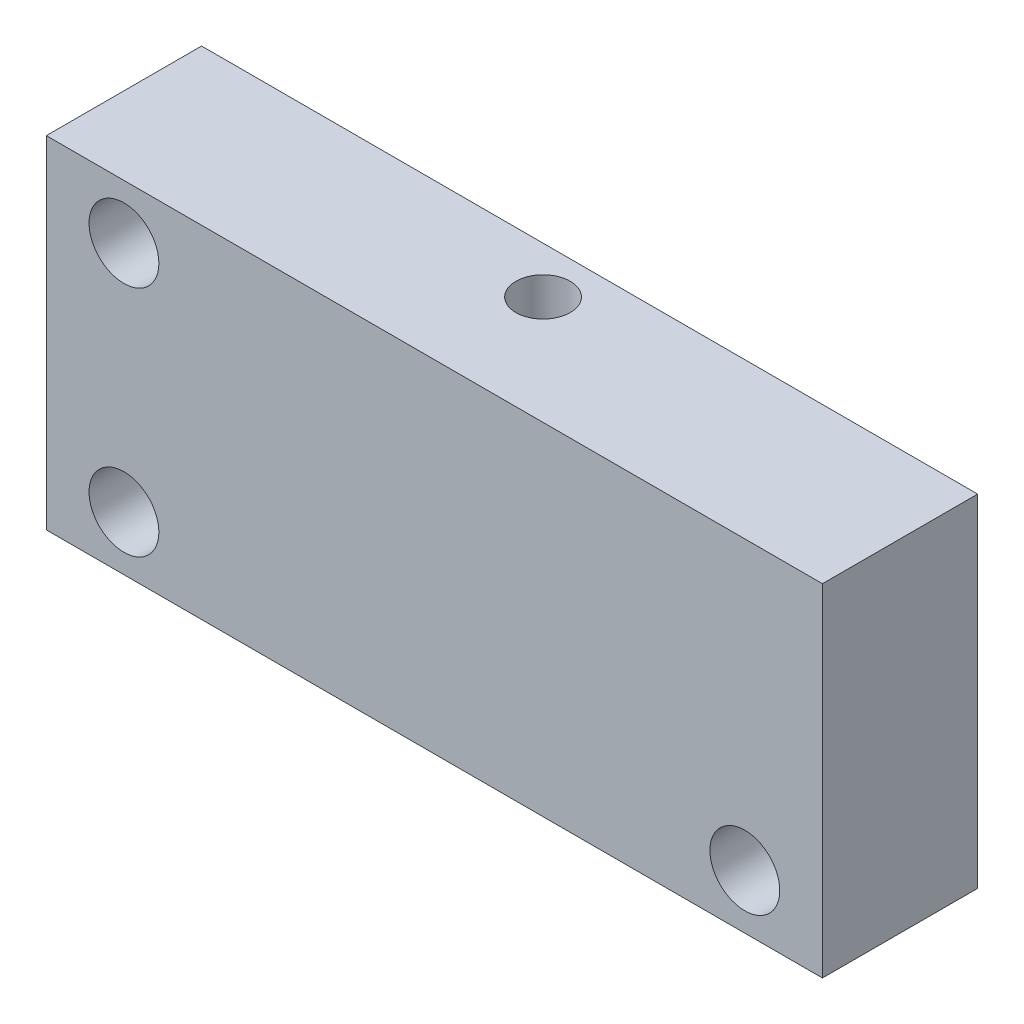
from build123d import *

# Parameters (mm, degrees)
SKIZZE1_W                       = 50
SKIZZE1_H                       = 22
AUFSATZ_LINEAR_AUSTRAGEN1_DEPTH = 10
SKIZZE2_R                       = 2.25
SCHNITT_LINEAR_AUSTRAGEN1_DEPTH = 11
SKIZZE3_W                       = 12.9
SKIZZE3_H                       = 12.9
SCHNITT_LINEAR_AUSTRAGEN2_DEPTH = 6
SKIZZE4_R                       = 2
SCHNITT_LINEAR_AUSTRAGEN3_DEPTH = 6.1
SKIZZE5_R                       = 1.75
SCHNITT_LINEAR_AUSTRAGEN4_DEPTH = 6.1


with BuildPart() as part:
    # Skizze1 → Aufsatz-Linear austragen1 (new body)
    with BuildSketch(Plane.XY):
        Rectangle(SKIZZE1_W, SKIZZE1_H)
    extrude(amount=AUFSATZ_LINEAR_AUSTRAGEN1_DEPTH)

    # Skizze2 → Schnitt-Linear austragen1 (cut, through all)
    with BuildSketch(Plane.XY.offset(10)):
        with Locations((-20, 7.5)):
            Circle(SKIZZE2_R)
        with Locations((-20, -7.5)):
            Circle(SKIZZE2_R)
        with Locations((20, -7.5)):
            Circle(SKIZZE2_R)
    extrude(amount=-SCHNITT_LINEAR_AUSTRAGEN1_DEPTH, mode=Mode.SUBTRACT)

    # Skizze3 → Schnitt-Linear austragen2 (cut)
    with BuildSketch(Plane(origin=(0, 0, 0), x_dir=(-1, 0, 0), z_dir=(0, 0, -1))):
        Rectangle(SKIZZE3_W, SKIZZE3_H)
    extrude(amount=-SCHNITT_LINEAR_AUSTRAGEN2_DEPTH, mode=Mode.SUBTRACT)

    # Skizze4 → Schnitt-Linear austragen3 (cut)
    with BuildSketch(Plane(origin=(0, 0, 0), x_dir=(-1, 0, 0), z_dir=(0, 0, -1))):
        with Locations((-6.45, 6.45)):
            Circle(SKIZZE4_R)
        with Locations((6.45, 6.45)):
            Circle(SKIZZE4_R)
        with Locations((-6.45, -6.45)):
            Circle(SKIZZE4_R)
        with Locations((6.45, -6.45)):
            Circle(SKIZZE4_R)
    extrude(amount=-SCHNITT_LINEAR_AUSTRAGEN3_DEPTH, mode=Mode.SUBTRACT)

    # Skizze5 → Schnitt-Linear austragen4 (cut)
    with BuildSketch(Plane(origin=(0, 11, 0), x_dir=(1, 0, 0), z_dir=(0, 1, 0))):
        with Locations((0, -3)):
            Circle(SKIZZE5_R)
    extrude(amount=-SCHNITT_LINEAR_AUSTRAGEN4_DEPTH, mode=Mode.SUBTRACT)


solid = part.part
